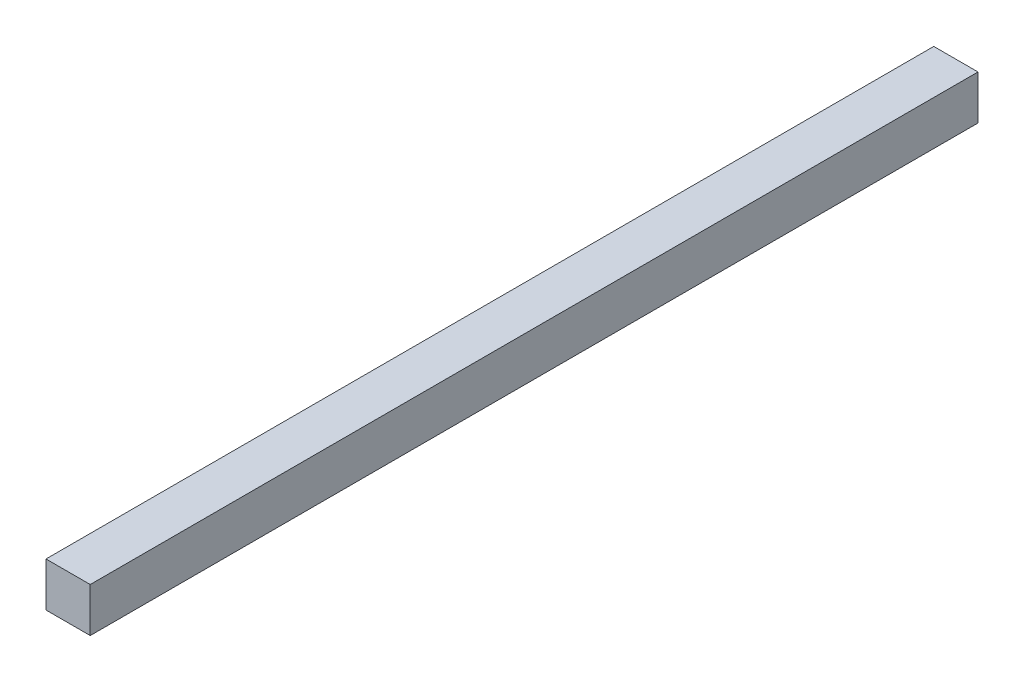
from build123d import *

# Parameters (mm, degrees)
SKETCH1_W           = 10
SKETCH1_H           = 10
BOSS_EXTRUDE1_DEPTH = 200.7


with BuildPart() as part:
    # Sketch1 → Boss-Extrude1 (new body)
    with BuildSketch(Plane.XY):
        Rectangle(SKETCH1_W, SKETCH1_H)
    extrude(amount=BOSS_EXTRUDE1_DEPTH)


solid = part.part
